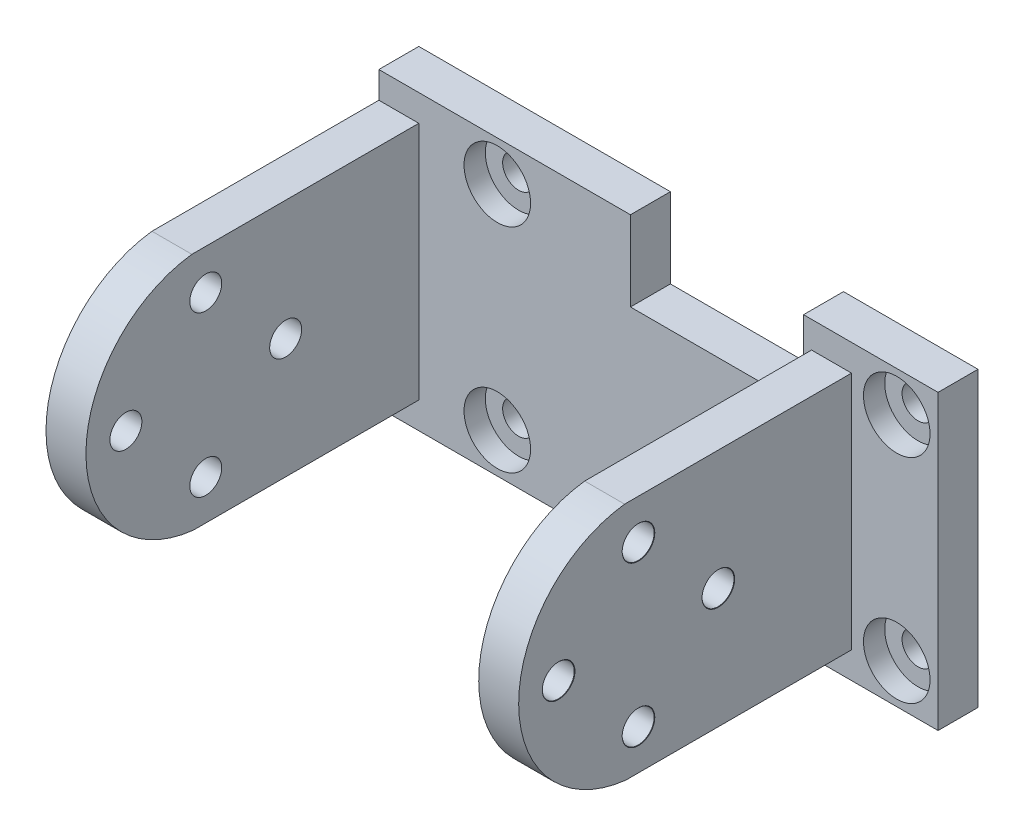
from build123d import *

# Parameters (mm, degrees)
SKETCH1_W                                        = 42
SKETCH1_H                                        = 22
BOSS_EXTRUDE1_DEPTH                              = 3
SKETCH2_W                                        = 13
SKETCH2_H                                        = 6
CUT_EXTRUDE1_DEPTH                               = 4
SKETCH3_W                                        = 13
SKETCH3_H                                        = 6
CUT_EXTRUDE2_DEPTH                               = 4
BOSS_EXTRUDE2_DEPTH                              = 3
BOSS_EXTRUDE3_DEPTH                              = 3
M2_CLEARANCE_HOLE1_D                             = 2.4
M2_CLEARANCE_HOLE1_CSINK_D                       = 2.45
M2_CLEARANCE_HOLE1_CSINK_ANGLE                   = 90
M2_CLEARANCE_HOLE2_D                             = 2.4
CBORE_FOR_M2_PAN_HEAD_MACHINE_SCREW2_D           = 2.4
CBORE_FOR_M2_PAN_HEAD_MACHINE_SCREW2_CBORE_D     = 5
CBORE_FOR_M2_PAN_HEAD_MACHINE_SCREW2_CBORE_DEPTH = 1.6


with BuildPart() as part:
    # Sketch1 → Boss-Extrude1 (new body)
    with BuildSketch(Plane.XY.offset(163.526991532)):
        with Locations((15.20664665, 218.33461514)):
            Rectangle(SKETCH1_W, SKETCH1_H)
    extrude(amount=-BOSS_EXTRUDE1_DEPTH)

    # Sketch2 → Cut-Extrude1 (cut, through all)
    with BuildSketch(Plane(origin=(0, 0, 160.526991532), x_dir=(-1, 0, 0), z_dir=(0, 0, -1))):
        with Locations((-19.603323325, 226.33461514)):
            Rectangle(SKETCH2_W, SKETCH2_H)
    extrude(amount=-CUT_EXTRUDE1_DEPTH, mode=Mode.SUBTRACT)

    # Sketch3 → Cut-Extrude2 (cut, through all)
    with BuildSketch(Plane(origin=(0, 0, 160.526991532), x_dir=(-1, 0, 0), z_dir=(0, 0, -1))):
        with Locations((-19.603323325, 210.33461514)):
            Rectangle(SKETCH3_W, SKETCH3_H)
    extrude(amount=-CUT_EXTRUDE2_DEPTH, mode=Mode.SUBTRACT)

    # Sketch4 → Boss-Extrude2 (add)
    with BuildSketch(Plane(origin=(-5.79335335, 0, 0), x_dir=(0, -1, 0), z_dir=(-1, 0, 0))):
        with BuildLine():
            Line((-227.33461514, 180.570138914), (-227.33461514, 163.526991532))
            Line((-227.33461514, 163.526991532), (-209.33461514, 163.526991532))
            Line((-209.33461514, 163.526991532), (-209.33461514, 180.47391761))
            ThreePointArc((-209.33461514, 180.47391761), (-218.291824267, 188.52686382), (-227.33461514, 180.570138914))
        make_face()
    extrude(amount=-BOSS_EXTRUDE2_DEPTH)

    # Sketch5 → Boss-Extrude3 (add)
    with BuildSketch(Plane(origin=(29.70664665, 0, 0), x_dir=(0, 0, -1), z_dir=(1, 0, 0))):
        with BuildLine():
            Line((-180.47391761, 209.33461514), (-163.526991532, 209.33461514))
            Line((-163.526991532, 209.33461514), (-163.526991532, 227.33461514))
            Line((-163.526991532, 227.33461514), (-180.570138914, 227.33461514))
            ThreePointArc((-180.570138914, 227.33461514), (-188.52686382, 218.291824267), (-180.47391761, 209.33461514))
        make_face()
    extrude(amount=-BOSS_EXTRUDE3_DEPTH)

    # M2 Clearance Hole1 (through all)
    with Locations(Plane(origin=(29.70664665, 0, 0), x_dir=(0, 0, -1), z_dir=(1, 0, 0))):
        with Locations((-179.527190494, 224.334217217), (-185.526991532, 218.334416179), (-179.527190494, 212.33461514), (-173.527389456, 218.334416179)):
            CounterSinkHole(M2_CLEARANCE_HOLE1_D / 2, M2_CLEARANCE_HOLE1_CSINK_D / 2, counter_sink_angle=M2_CLEARANCE_HOLE1_CSINK_ANGLE)

    # M2 Clearance Hole2 (through all)
    with Locations(Plane.XY.offset(163.526991532)):
        with Locations((3.103323325, 226.326974637), (3.103323325, 210.326974637), (33.103323325, 210.326974637), (33.103323325, 226.326974637)):
            Hole(M2_CLEARANCE_HOLE2_D / 2)

    # CBORE for M2 Pan Head Machine Screw2 (through all)
    with Locations(Plane.XY.offset(163.526991532)):
        with Locations((3.103323325, 226.326974637), (3.103323325, 210.326974637), (33.103323325, 226.326974637), (33.103323325, 210.326974637)):
            CounterBoreHole(CBORE_FOR_M2_PAN_HEAD_MACHINE_SCREW2_D / 2, CBORE_FOR_M2_PAN_HEAD_MACHINE_SCREW2_CBORE_D / 2, CBORE_FOR_M2_PAN_HEAD_MACHINE_SCREW2_CBORE_DEPTH)


solid = part.part
